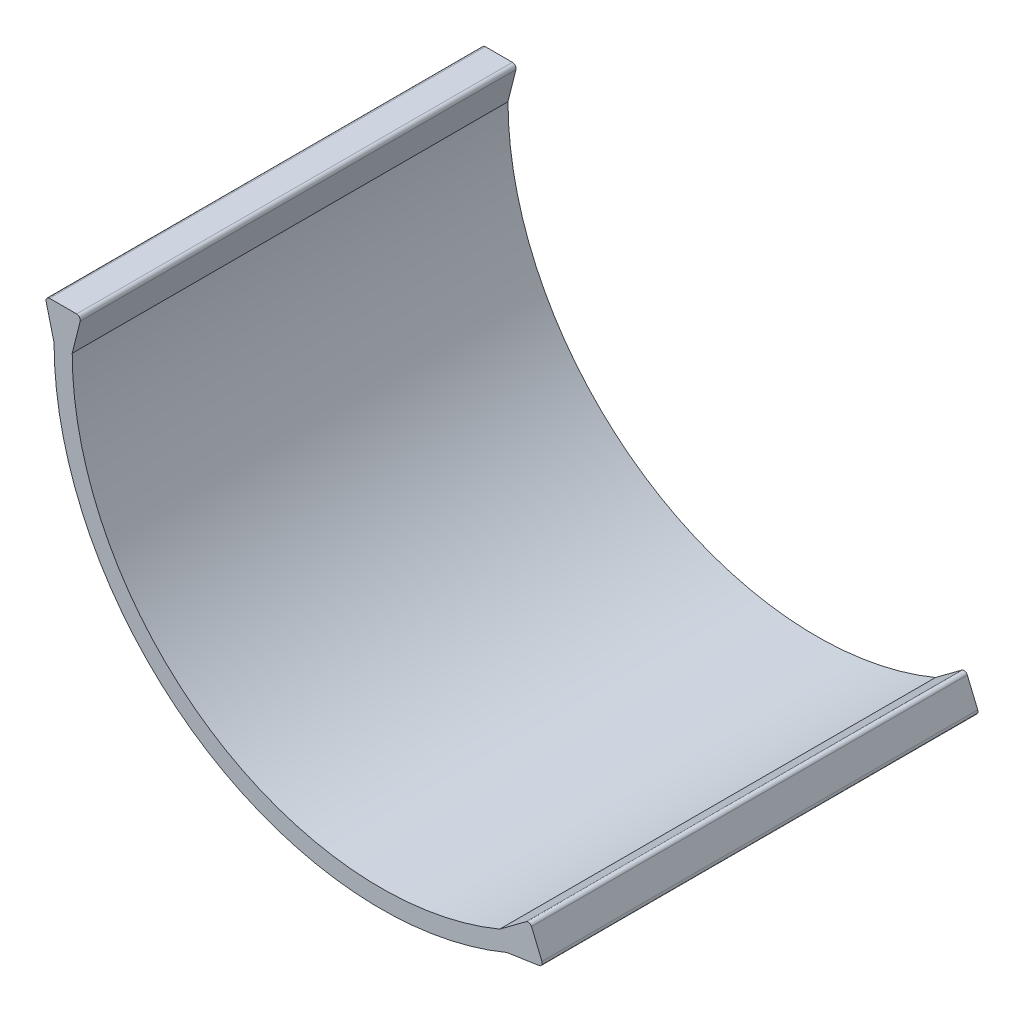
from build123d import *

# Parameters (mm, degrees)
MAIN_BODY_DEPTH           = 120
LOCKING_MECHANISM_DEPTH   = 120
LOCKING_MECHANISM_2_DEPTH = 120


with BuildPart() as part:
    # Curve → Main Body (new body)
    with BuildSketch(Plane.XY):
        with BuildLine():
            ThreePointArc((-85, 0), (-47.139087644, -70.731226598), (32.715445084, -78.451893877))
            Line((32.715445084, -78.451893877), (34.63988303, -83.066711164))
            ThreePointArc((34.63988303, -83.066711164), (-49.911975153, -74.891886986), (-90, 0))
            Line((-90, 0), (-85, 0))
        make_face()
    extrude(amount=MAIN_BODY_DEPTH)

    # Lock shape → Locking Mechanism (add)
    with BuildSketch(Plane.XY.offset(120)):
        with BuildLine():
            Line((32.715445084, -78.451893877), (39.955604844, -73.060549627))
            ThreePointArc((39.955604844, -73.060549627), (40.81748466, -72.898257413), (41.475815628, -73.477719162))
            Line((41.475815628, -73.477719162), (44.338781633, -80.343134095))
            ThreePointArc((44.338781633, -80.343134095), (44.287191647, -81.218641979), (43.565362465, -81.716776713))
            Line((43.565362465, -81.716776713), (34.63988303, -83.066711164))
            Line((34.63988303, -83.066711164), (32.715445084, -78.451893877))
        make_face()
    extrude(amount=-LOCKING_MECHANISM_DEPTH)

    # Lock shape 2 → Locking Mechanism 2 (add)
    with BuildSketch(Plane.XY.offset(120)):
        with BuildLine():
            Line((-90, 0), (-92.189366094, 8.757464375))
            ThreePointArc((-92.189366094, 8.757464375), (-92.007429032, 9.615412209), (-91.219223594, 10))
            Line((-91.219223594, 10), (-83.780776406, 10))
            ThreePointArc((-83.780776406, 10), (-82.992570968, 9.615412209), (-82.810633906, 8.757464375))
            Line((-82.810633906, 8.757464375), (-85, 0))
            Line((-85, 0), (-90, 0))
        make_face()
    extrude(amount=-LOCKING_MECHANISM_2_DEPTH)


solid = part.part
